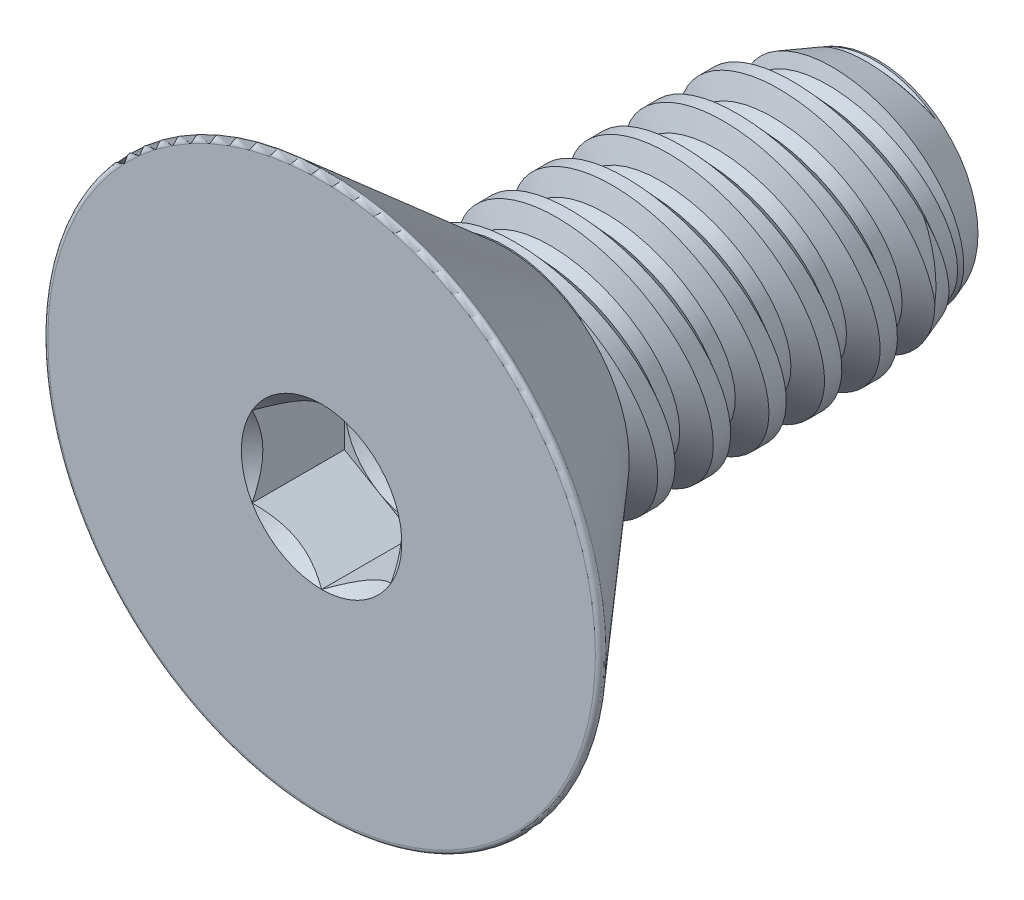
from build123d import *

# Parameters (mm, degrees)
SKETCH1_W          = 4.2418
SKETCH1_H          = 1.4224
LPATTERN1_COUNT    = 7
LPATTERN1_PITCH    = 0.635
LPATTERN2_COUNT    = 2
LPATTERN2_PITCH    = 0.635
SKETCH4_R          = 3.2385
EXTRUDE1_DEPTH     = 2.1082
FILLET1_R          = 0.0508
CUT_EXTRUDE1_DEPTH = 1.0541
SKETCH7_R          = 0.916543552
CUT_EXTRUDE4_DEPTH = 1.0541
CUT_EXTRUDE4_DRAFT = -45
SKETCH8_R          = 0.79375
CUT_EXTRUDE5_DEPTH = 0.351366667
CUT_EXTRUDE5_TAPER = 60


with BuildPart() as part:
    # Sketch1 → Revolve1 (revolve)
    with BuildSketch(Plane(origin=(0, 0, 0), x_dir=(0, 0, -1), z_dir=(1, 0, 0))):
        with Locations((2.1209, 0.7112)):
            Rectangle(SKETCH1_W, SKETCH1_H)
    revolve(axis=Axis((0, 0, 0), (0, 0, 1)))

    # Sketch2 → Cut-Revolve1 (revolve, cut)
    with BuildSketch(Plane(origin=(0, 0, 0), x_dir=(0, 0, -1), z_dir=(1, 0, 0))):
        Polygon((0.077468538, 1.439692084), (0.619748307, 1.560736676), (0.500953883, 1.182057853), (0.346016806, 1.147473684), align=None)
    cut_revolve1 = revolve(axis=Axis((0, -0.152561988, 0), (0, 0.217853033, -0.975981586)), mode=Mode.SUBTRACT)

    # Sketch3 → Cut-Revolve2 (revolve, cut)
    with BuildSketch(Plane(origin=(0, 0, 0), x_dir=(0, 0, -1), z_dir=(1, 0, 0))):
        Polygon((4.2418, 1.147473684), (3.486446156, 1.4224), (4.2418, 1.4224), align=None)
    revolve(axis=Axis((0, 0, -3.486446156), (0, 0, 1)), mode=Mode.SUBTRACT)

    # LPattern1: Cut-Revolve1 ×7
    with Locations(*[(0, 0, -i * LPATTERN1_PITCH) for i in range(1, LPATTERN1_COUNT)]):
        add(cut_revolve1, mode=Mode.SUBTRACT)

    # LPattern2: Cut-Revolve1 ×2
    with Locations(*[(0, 0, i * LPATTERN2_PITCH) for i in range(1, LPATTERN2_COUNT)]):
        add(cut_revolve1, mode=Mode.SUBTRACT)

    # Sketch4 → Extrude1 (add)
    with BuildSketch(Plane.XY):
        Circle(SKETCH4_R)
    extrude(amount=EXTRUDE1_DEPTH)

    # Sketch9 → Cut-Revolve3 (revolve, cut)
    with BuildSketch(Plane(origin=(0, 0, 0), x_dir=(0, 0, -1), z_dir=(1, 0, 0))):
        Polygon((-2.1082, 3.2385), (0, 1.405869699), (0, 3.2385), align=None)
    revolve(axis=Axis((0, 0, 0), (0, 0, 1)), mode=Mode.SUBTRACT)

    # Fillet1
    fillet1_edges = [part.edges().sort_by_distance(p)[0] for p in [
        (0, -3.2385, 2.1082),
    ]]
    fillet(fillet1_edges, radius=FILLET1_R)

    # Sketch6 → Cut-Extrude1 (cut)
    with BuildSketch(Plane.XY.offset(2.1082)):
        Polygon((0, -0.916543552), (0.79375, -0.458271776), (0.79375, 0.458271776), (0, 0.916543552), (-0.79375, 0.458271776), (-0.79375, -0.458271776), align=None)
    extrude(amount=-CUT_EXTRUDE1_DEPTH, mode=Mode.SUBTRACT)


with BuildPart() as cut_extrude4_tool:
    # Sketch7 → Cut-Extrude4 (with draft: the straight prism first)
    with BuildSketch(Plane.XY.offset(2.1082)):
        Circle(SKETCH7_R)
    extrude(amount=-CUT_EXTRUDE4_DEPTH)
    # Cut-Extrude4: the draft: its side faces are tilted about the plane it starts from
    cut_extrude4_sides = [cut_extrude4_tool.faces().sort_by_distance(p)[0] for p in [
        (-0.916543552, 0, 1.58115),
    ]]
    draft(cut_extrude4_sides, Plane.XY.offset(2.1082), CUT_EXTRUDE4_DRAFT)


with BuildPart() as part_1:
    add(part.part)

    # Cut-Extrude4: cut by cut_extrude4_tool
    add(cut_extrude4_tool.part, mode=Mode.SUBTRACT)

    # Sketch8 → Cut-Extrude5 (cut)
    with BuildSketch(Plane.XY.offset(1.0541)):
        Circle(SKETCH8_R)
    extrude(amount=-CUT_EXTRUDE5_DEPTH, taper=CUT_EXTRUDE5_TAPER, mode=Mode.SUBTRACT)


solid = part_1.part
